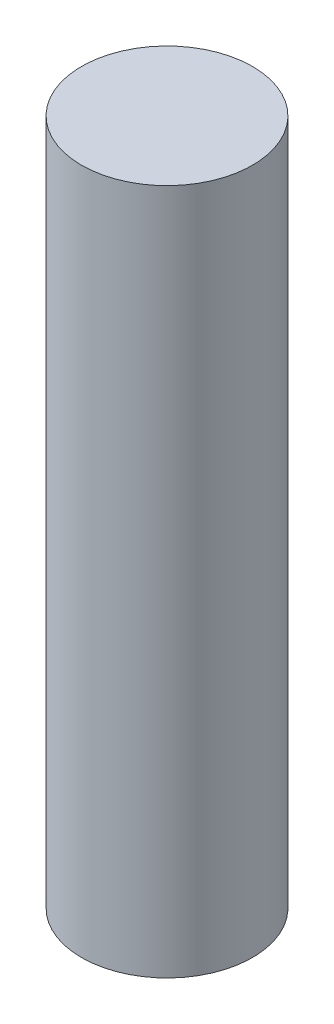
from build123d import *

# Parameters (mm, degrees)
SKETCH3_R           = 0.935
BOSS_EXTRUDE1_DEPTH = 7.5


with BuildPart() as part:
    # Sketch3 → Boss-Extrude1 (new body)
    with BuildSketch(Plane(origin=(0, 0, 0), x_dir=(1, 0, 0), z_dir=(0, 1, 0))):
        Circle(SKETCH3_R)
    extrude(amount=BOSS_EXTRUDE1_DEPTH)


solid = part.part
